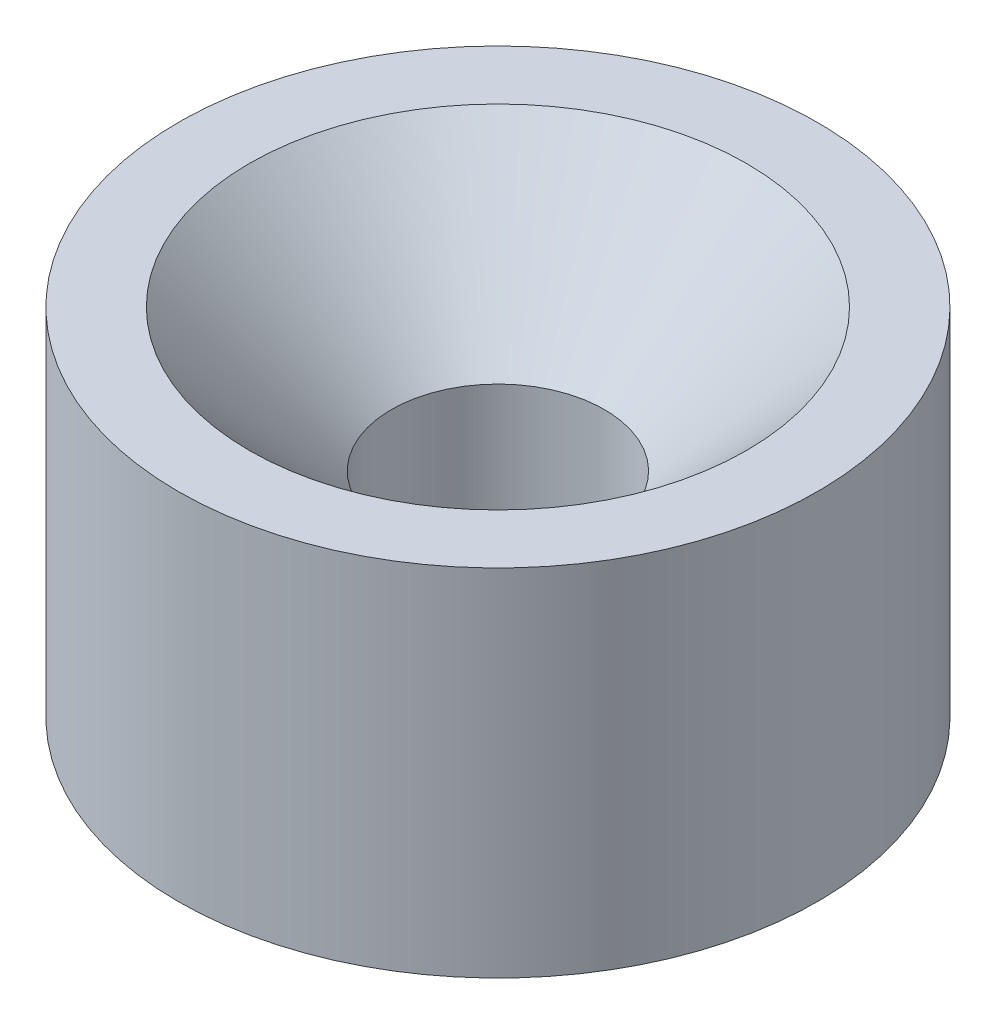
from build123d import *

# Parameters (mm, degrees)
SKETCH1_R           = 4.5
SKETCH1_R_2         = 1.5
BOSS_EXTRUDE1_DEPTH = 5
CHAMFER1_SIZE       = 2


with BuildPart() as part:
    # Sketch1 → Boss-Extrude1 (new body)
    with BuildSketch(Plane(origin=(0, 0, 0), x_dir=(1, 0, 0), z_dir=(0, 1, 0))):
        Circle(SKETCH1_R)
        Circle(SKETCH1_R_2, mode=Mode.SUBTRACT)
    extrude(amount=BOSS_EXTRUDE1_DEPTH)

    # Chamfer1
    chamfer1_edges = [part.edges().sort_by_distance(p)[0] for p in [
        (-1.5, 5, 0),
    ]]
    chamfer(chamfer1_edges, length=CHAMFER1_SIZE)


solid = part.part
